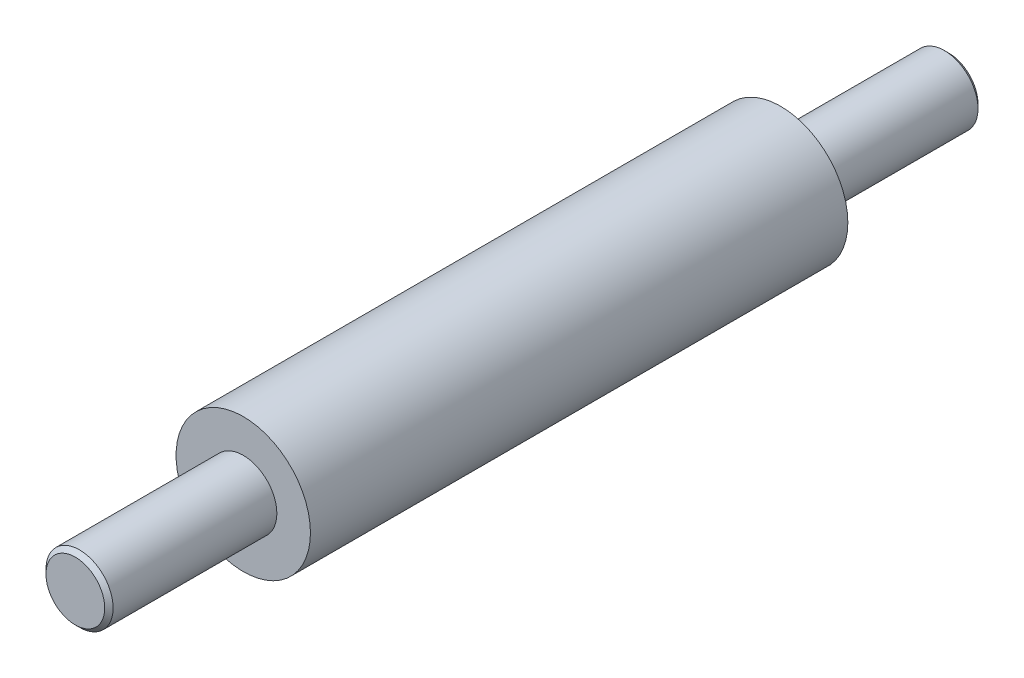
from build123d import *

# Parameters (mm, degrees)
ESQUISSE1_R                  = 4
BOSS_EXTRU_1_DEPTH           = 16
ESQUISSE2_R                  = 2
BOSS_EXTRU_2_DEPTH           = 10
CHANFREIN1_SIZE              = 0.25
CHANFREIN1_OF_SYM_TRIE1_SIZE = 0.25


with BuildPart() as part:
    # Esquisse1 → Boss.-Extru.1 (new body, symmetric)
    with BuildSketch(Plane.XY):
        Circle(ESQUISSE1_R)
    extrude(amount=BOSS_EXTRU_1_DEPTH, both=True)

    # Esquisse2 → Boss.-Extru.2 (add)
    with BuildSketch(Plane.XY.offset(16)):
        Circle(ESQUISSE2_R)
    boss_extru_2 = extrude(amount=BOSS_EXTRU_2_DEPTH)

    # Chanfrein1
    chanfrein1_edges = [part.edges().sort_by_distance(p)[0] for p in [
        (-2, 0, 26),
    ]]
    chamfer(chanfrein1_edges, length=CHANFREIN1_SIZE)

    # Symétrie1: Boss.-Extru.2 across plane
    add(boss_extru_2.mirror(Plane.XY))

    # Chanfrein1 of Symétrie1
    chanfrein1_of_sym_trie1_edges = [part.edges().sort_by_distance(p)[0] for p in [
        (-2, 0, -26),
    ]]
    chamfer(chanfrein1_of_sym_trie1_edges, length=CHANFREIN1_OF_SYM_TRIE1_SIZE)


solid = part.part
